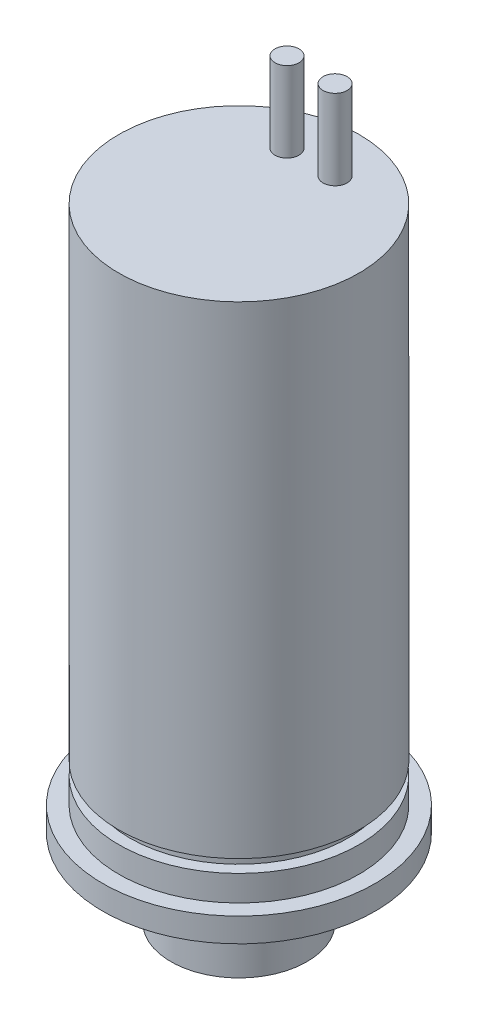
from build123d import *

# Parameters (mm, degrees)
SKETCH2_R           = 0.75
BOSS_EXTRUDE1_DEPTH = 5
SKETCH3_W           = 0.99
SKETCH3_H           = 0.65
SKETCH4_R           = 1.17
CUT_EXTRUDE1_DEPTH  = 7.5
SKETCH5_W           = 1.13
SKETCH5_H           = 0.9
SKETCH_N_W          = 0.8
SKETCH_N_H          = 0.8


with BuildPart() as part:
    # Sketch1 → Revolve2 (revolve)
    with BuildSketch(Plane.XY):
        Polygon((0, 0), (-4.25, 0), (-4.25, 5.5), (-8.5, 5.5), (-8.5, 7), (-7.5, 7), (-7.5, 39.5), (0, 39.5), align=None)
    revolve(axis=Axis((0, 0, 0), (0, 1, 0)))

    # Sketch2 → Boss-Extrude1 (add)
    with BuildSketch(Plane(origin=(0, 39.5, 0), x_dir=(1, 0, 0), z_dir=(0, 1, 0))):
        with Locations((1.5, 4.5)):
            Circle(SKETCH2_R)
        with Locations((-1.5, 4.5)):
            Circle(SKETCH2_R)
    extrude(amount=BOSS_EXTRUDE1_DEPTH)

    # Sketch3 → Cut-Revolve1 (revolve, cut)
    with BuildSketch(Plane(origin=(0, 0, 0), x_dir=(0, 0, -1), z_dir=(1, 0, 0))):
        with Locations((3.755, 0.325)):
            Rectangle(SKETCH3_W, SKETCH3_H)
    revolve(axis=Axis((0, 0, 0), (0, 1, 0)), mode=Mode.SUBTRACT)

    # Sketch4 → Cut-Extrude1 (cut)
    with BuildSketch(Plane.XZ):
        Circle(SKETCH4_R)
    extrude(amount=-CUT_EXTRUDE1_DEPTH, mode=Mode.SUBTRACT)

    # Sketch5 → Cut-Revolve2 (revolve, cut)
    with BuildSketch(Plane(origin=(0, 0, 0), x_dir=(0, 0, -1), z_dir=(1, 0, 0))):
        with Locations((7.065, 5.95)):
            Rectangle(SKETCH5_W, SKETCH5_H)
    revolve(axis=Axis((0, 0, 0), (0, 1, 0)), mode=Mode.SUBTRACT)

    # Sketch N → Cut-Revolve8 (revolve, cut)
    with BuildSketch(Plane(origin=(0, 0, 0), x_dir=(0, 0, -1), z_dir=(1, 0, 0))):
        with Locations((7.2, 9)):
            Rectangle(SKETCH_N_W, SKETCH_N_H)
    revolve(axis=Axis((0, 0, 0), (0, 1, 0)), mode=Mode.SUBTRACT)


solid = part.part
